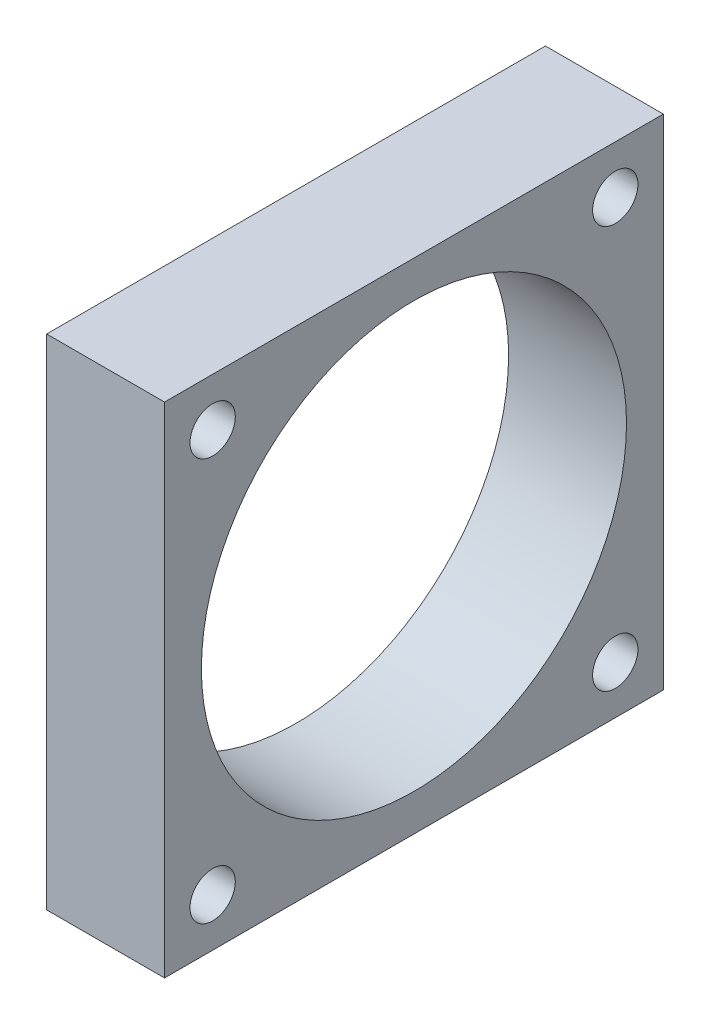
from build123d import *

# Parameters (mm, degrees)
SKETCH1_W               = 55.88
SKETCH1_H               = 55.88
SKETCH1_R               = 23.8125
BOSS_EXTRUDE1_DEPTH     = 13.208
SKETCH5_R               = 2.54
CUT_EXTRUDE2_DEPTH      = 14.208
CUT_EXTRUDE2_DEPTH_BACK = 1


with BuildPart() as part:
    # Sketch1 → Boss-Extrude1 (new body)
    with BuildSketch(Plane(origin=(0, 0, 0), x_dir=(0, 0, -1), z_dir=(1, 0, 0))):
        Rectangle(SKETCH1_W, SKETCH1_H)
        Circle(SKETCH1_R, mode=Mode.SUBTRACT)
    extrude(amount=BOSS_EXTRUDE1_DEPTH)

    # Sketch5 → Cut-Extrude2 (cut, two sides)
    with BuildSketch(Plane(origin=(0, 0, 0), x_dir=(0, 0, -1), z_dir=(1, 0, 0))) as cut_extrude2_sk:
        with Locations((-22.551846327, -22.551846327)):
            Circle(SKETCH5_R)
        with Locations((-22.551846327, 22.551846327)):
            Circle(SKETCH5_R)
        with Locations((22.551846327, 22.551846327)):
            Circle(SKETCH5_R)
        with Locations((22.551846327, -22.551846327)):
            Circle(SKETCH5_R)
    extrude(amount=CUT_EXTRUDE2_DEPTH, mode=Mode.SUBTRACT)
    extrude(cut_extrude2_sk.sketch, amount=-CUT_EXTRUDE2_DEPTH_BACK, mode=Mode.SUBTRACT)


solid = part.part
